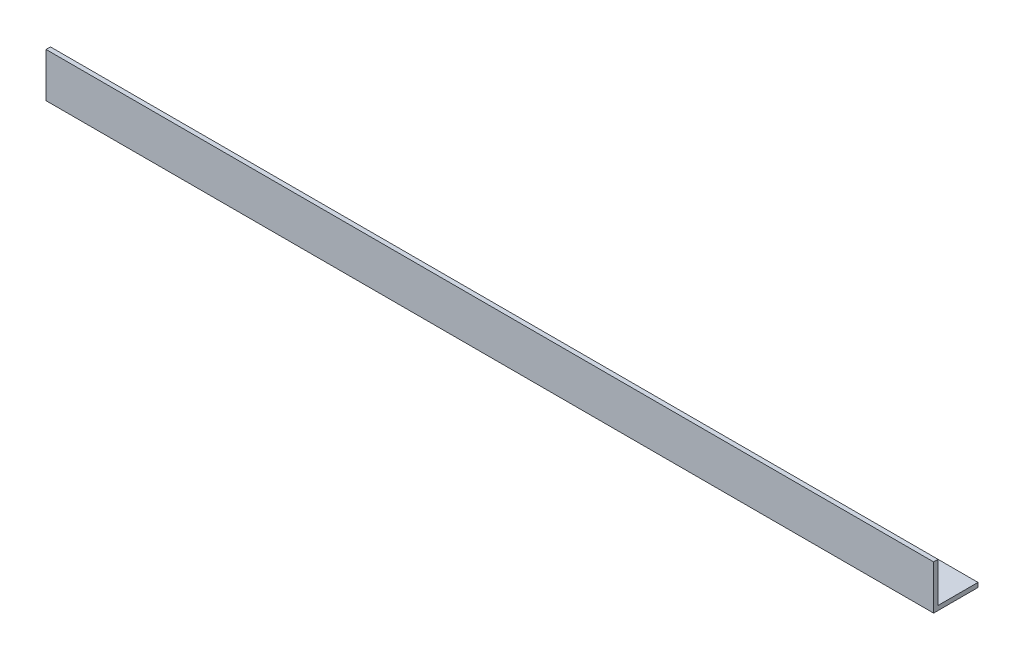
from build123d import *

# Parameters (mm, degrees)
EXTRUDE_1_DEPTH = 300


with BuildPart() as part:
    # Эскиз1 → Бобышка-Вытянуть1 (new body)
    with BuildSketch(Plane(origin=(0, 0, 0), x_dir=(0, 0, -1), z_dir=(1, 0, 0))):
        Polygon((0, 0), (0, 15), (1.5, 15), (1.5, 1.5), (15, 1.5), (15, 0), align=None)
    extrude(amount=EXTRUDE_1_DEPTH)


solid = part.part
